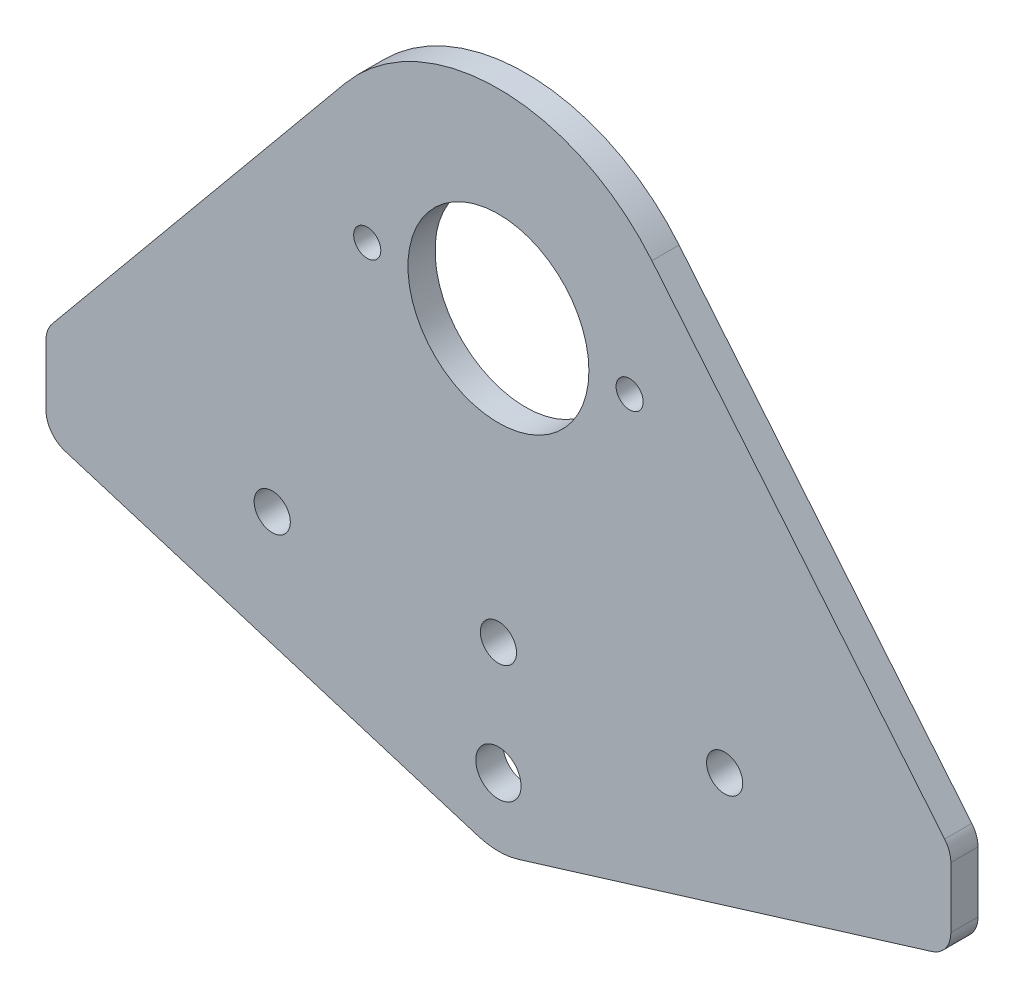
from build123d import *

# Parameters (mm, degrees)
SKETCH1_R           = 2
SKETCH1_R_2         = 2.5
SKETCH1_R_3         = 1.5
SKETCH1_R_4         = 10
BOSS_EXTRUDE1_DEPTH = 3
FILLET1_R           = 3


with BuildPart() as part:
    # Sketch1 → Boss-Extrude1 (new body)
    with BuildSketch(Plane.XY):
        with BuildLine():
            Line((-50, -26), (-50, -36))
            Line((-50, -36), (-2.200488998, -50.66992665))
            ThreePointArc((-2.200488998, -50.66992665), (0, -51), (2.200488998, -50.66992665))
            Line((2.200488998, -50.66992665), (50, -36))
            Line((50, -36), (50, -26))
            Line((50, -26), (16.964082686, 14.00785132))
            ThreePointArc((16.964082686, 14.00785132), (0, 22), (-16.964082686, 14.00785132))
            Line((-16.964082686, 14.00785132), (-50, -26))
        make_face()
        with Locations((-25, -31)):
            Circle(SKETCH1_R, mode=Mode.SUBTRACT)
        with Locations((0, -31)):
            Circle(SKETCH1_R, mode=Mode.SUBTRACT)
        with Locations((25, -31)):
            Circle(SKETCH1_R, mode=Mode.SUBTRACT)
        with Locations((0, -43.5)):
            Circle(SKETCH1_R_2, mode=Mode.SUBTRACT)
        with Locations((14.5, 0)):
            Circle(SKETCH1_R_3, mode=Mode.SUBTRACT)
        Circle(SKETCH1_R_4, mode=Mode.SUBTRACT)
        with Locations((-14.5, 0)):
            Circle(SKETCH1_R_3, mode=Mode.SUBTRACT)
    extrude(amount=BOSS_EXTRUDE1_DEPTH)

    # Fillet1
    fillet1_edges = [part.edges().sort_by_distance(p)[0] for p in [
        (-50, -36, 1.5),
        (-50, -26, 1.5),
        (50, -26, 1.5),
        (50, -36, 1.5),
    ]]
    fillet(fillet1_edges, radius=FILLET1_R)


solid = part.part
